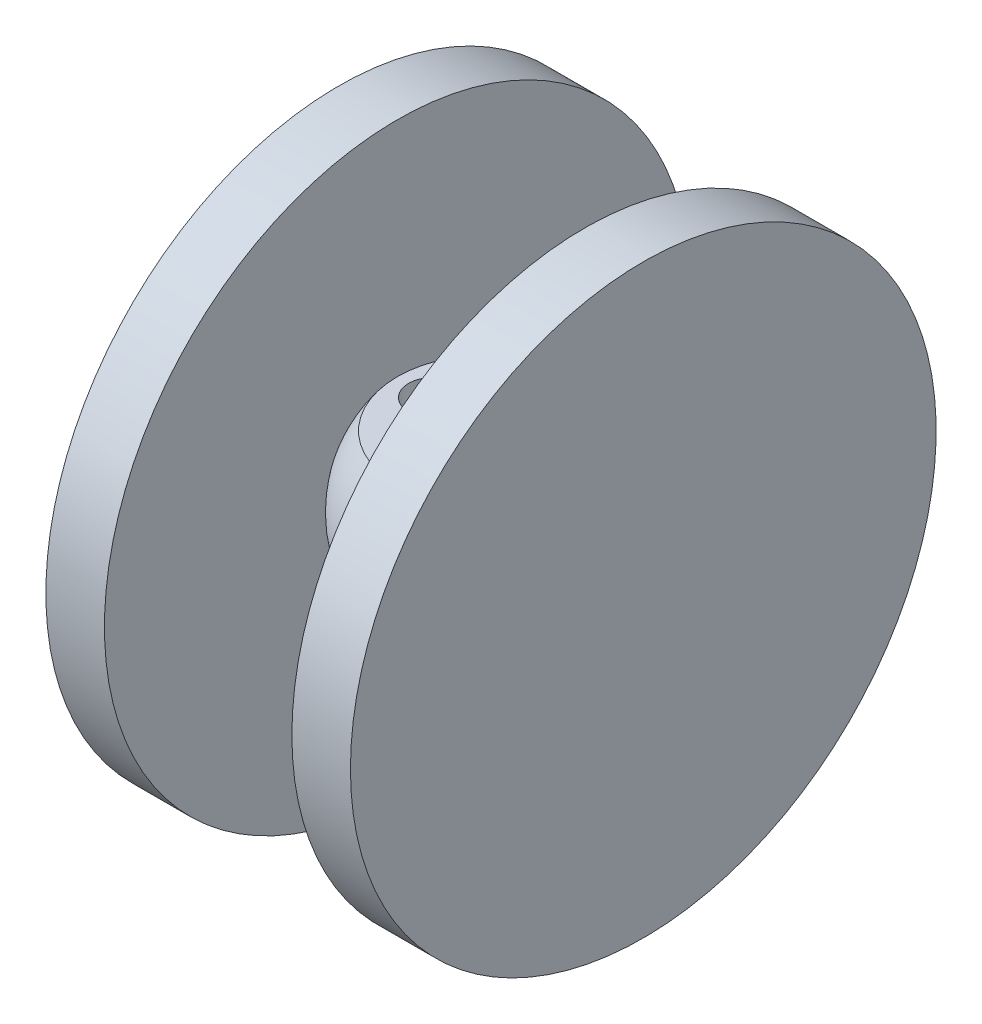
from build123d import *
from OCP.BRepFilletAPI import BRepFilletAPI_MakeChamfer

# Parameters (mm, degrees)
CUT_EXTRUDE1_DEPTH      = 35.641016151
CUT_EXTRUDE1_DEPTH_BACK = 10
SKETCH2_R               = 4.25
CUT_EXTRUDE2_DEPTH      = 35.641016151
CUT_EXTRUDE2_DEPTH_BACK = 10
SKETCH3_R               = 4.25
CHAMFER1_SIZE           = 10
CHAMFER1_SIZE2          = 0.174550649
SKETCH4_OUTSIDE_W       = 54.998
SKETCH4_OUTSIDE_H       = 54.998
SKETCH4_OUTSIDE_W_2     = 32
SKETCH4_OUTSIDE_H_2     = 40
CUT_EXTRUDE3_DEPTH      = 43.708313008
SKETCH5_R               = 50
BOSS_EXTRUDE1_DEPTH     = 10
BOSS_EXTRUDE2_START     = -10
SKETCH6_R               = 50
BOSS_EXTRUDE2_DEPTH     = 10


with BuildPart() as part:
    # Sketch1 → Revolve2 (revolve)
    with BuildSketch(Plane(origin=(0, 0, 0), x_dir=(0, 0, -1), z_dir=(1, 0, 0))):
        with BuildLine():
            Line((0, 12), (16, 12))
            ThreePointArc((16, 12), (17.88854382, -8.94427191), (0, -20))
            Line((0, -20), (0, 12))
        make_face()
    revolve(axis=Axis((0, -20, 0), (0, 1, 0)))

    # Sketch2 → Cut-Extrude1 (cut, two sides: drawn at the far end of the back side and taken through both)
    with BuildSketch(Plane(origin=(0, 0, 0), x_dir=(0, 0, 1), z_dir=(0.13917310096006574, 0.9902680687415703, 0)).offset(-CUT_EXTRUDE1_DEPTH_BACK)):
        with Locations((0, 8)):
            Circle(SKETCH2_R)
    extrude(amount=CUT_EXTRUDE1_DEPTH + CUT_EXTRUDE1_DEPTH_BACK, mode=Mode.SUBTRACT)

    # Sketch3 → Cut-Extrude2 (cut, two sides: drawn at the far end of the back side and taken through both)
    with BuildSketch(Plane(origin=(0, 0, 0), x_dir=(0, 0, 1), z_dir=(-0.13917310096006574, 0.9902680687415703, 0)).offset(-CUT_EXTRUDE2_DEPTH_BACK)):
        with Locations((0, -8)):
            Circle(SKETCH3_R)
    extrude(amount=CUT_EXTRUDE2_DEPTH + CUT_EXTRUDE2_DEPTH_BACK, mode=Mode.SUBTRACT)

    # Chamfer1: one chamfer whose edges measure the first distance from different faces: ONE call of the kernel's chamfer builder (chamfer() names one face for all edges)
    chamfer1_edges_1 = [part.edges().sort_by_distance(p)[0] for p in [
        (6.53041354, -11.016065495, -4.25),
    ]]
    chamfer1_side_1 = [part.faces().sort_by_distance(p)[0] for p in [
        (8.197713558, 0.847390567, -4.25),
    ]]
    chamfer1_edges_2 = [part.edges().sort_by_distance(p)[0] for p in [
        (-6.53041354, -11.016065495, -4.25),
    ]]
    chamfer1_side_2 = [part.faces().sort_by_distance(p)[0] for p in [
        (-8.197713558, 0.847390567, -4.25),
    ]]
    chamfer1 = BRepFilletAPI_MakeChamfer(part.part.solid().wrapped)
    for e in chamfer1_edges_1:
        chamfer1.Add(CHAMFER1_SIZE, CHAMFER1_SIZE2, e.wrapped, chamfer1_side_1[0].wrapped)  # the first distance lies on this face
    for e in chamfer1_edges_2:
        chamfer1.Add(CHAMFER1_SIZE, CHAMFER1_SIZE2, e.wrapped, chamfer1_side_2[0].wrapped)  # the first distance lies on this face
    add(Compound.cast(chamfer1.Shape()), mode=Mode.REPLACE)

    # Sketch4 outside → Cut-Extrude3 (cut, through all)
    with BuildSketch(Plane(origin=(0, 12, 0), x_dir=(1, 0, 0), z_dir=(0, 1, 0))):
        Rectangle(SKETCH4_OUTSIDE_W, SKETCH4_OUTSIDE_H)
        Rectangle(SKETCH4_OUTSIDE_W_2, SKETCH4_OUTSIDE_H_2, mode=Mode.SUBTRACT)
    extrude(amount=-CUT_EXTRUDE3_DEPTH, mode=Mode.SUBTRACT)

    # Sketch5 → Boss-Extrude1 (add)
    with BuildSketch(Plane(origin=(-16, 0, -32), x_dir=(0, 0, -1), z_dir=(1, 0, 0))):
        with Locations((-32, 0)):
            Circle(SKETCH5_R)
    extrude(amount=-BOSS_EXTRUDE1_DEPTH)

    # Sketch6 → Boss-Extrude2 (add)
    with BuildSketch(Plane(origin=(16, 0, 32), x_dir=(0, 0, 1), z_dir=(-1, 0, 0)).offset(BOSS_EXTRUDE2_START)):
        with Locations((-32, 0)):
            Circle(SKETCH6_R)
    extrude(amount=BOSS_EXTRUDE2_DEPTH)


solid = part.part
